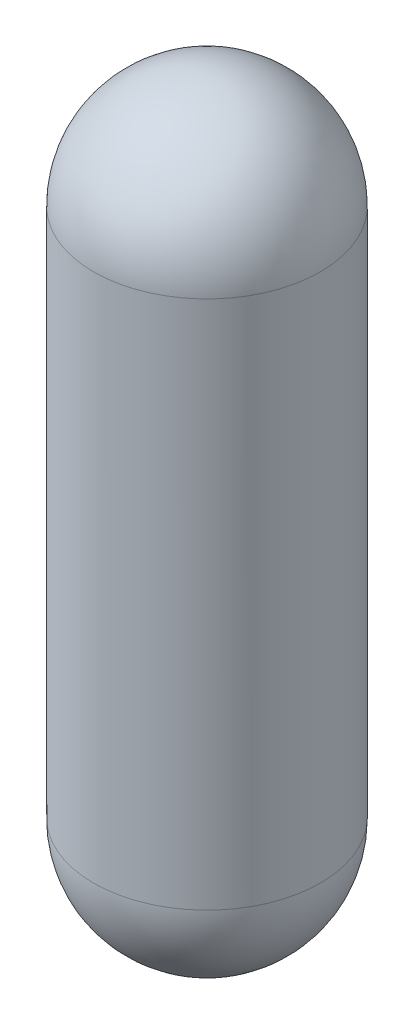
from build123d import *


with BuildPart() as part:
    # Sketch2 → Revolve6 (revolve)
    with BuildSketch(Plane.XY):
        with BuildLine():
            Line((7.5, -17.5), (7.5, 17.5))
            ThreePointArc((7.5, 17.5), (5.303300859, 22.803300859), (0, 25))
            Line((0, 25), (0, -25))
            ThreePointArc((0, -25), (5.303300859, -22.803300859), (7.5, -17.5))
        make_face()
    revolve(axis=Axis((0, 17.5, 0), (0, -1, 0)))


solid = part.part
